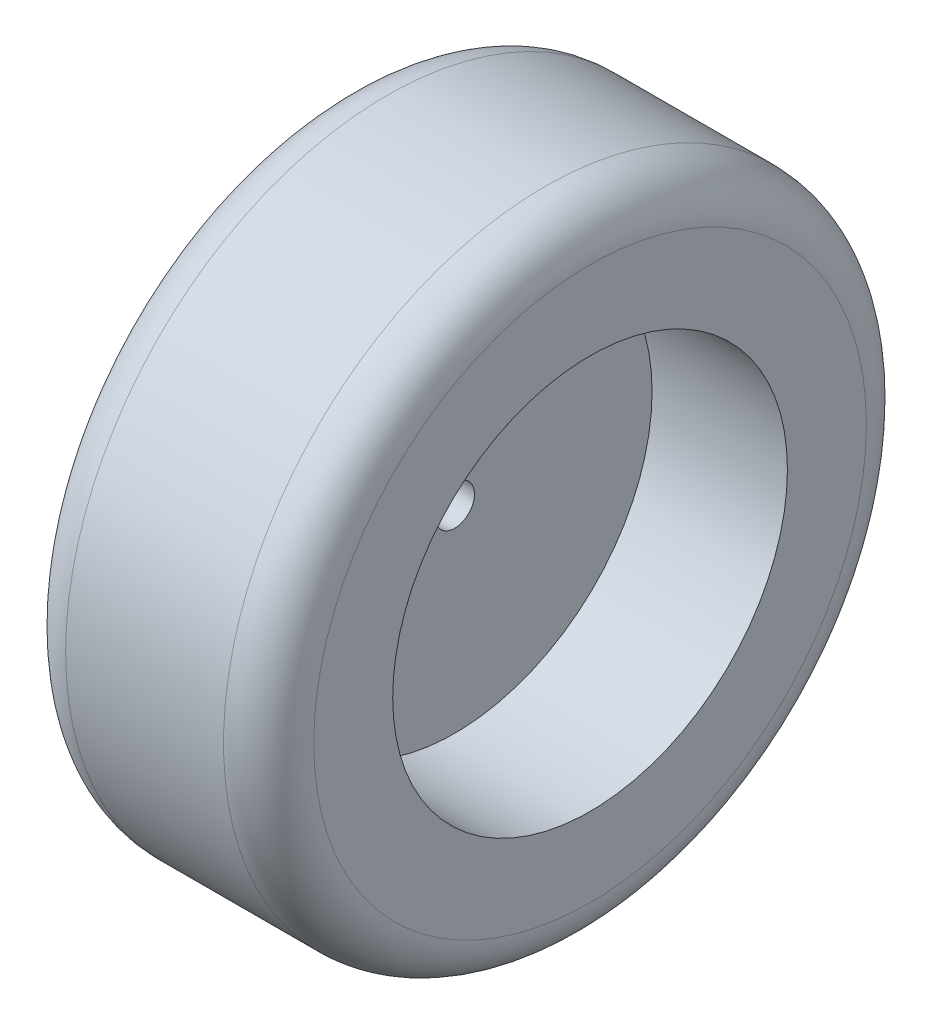
from build123d import *

# Parameters (mm, degrees)
SKETCH1_W          = 22
SKETCH1_H          = 28.5
FILLET1_R          = 4
SKETCH2_R          = 17.5
CUT_EXTRUDE1_DEPTH = 12
SKETCH3_R          = 17.5
CUT_EXTRUDE2_DEPTH = 8
SKETCH4_R          = 1.75
CUT_EXTRUDE3_DEPTH = 11


with BuildPart() as part:
    # Sketch1 → Revolve1 (revolve)
    with BuildSketch(Plane(origin=(0, 0, 0), x_dir=(1, 0, 0), z_dir=(0, 1, 0))):
        with Locations((0, 14.25)):
            Rectangle(SKETCH1_W, SKETCH1_H)
    revolve(axis=Axis((11, 0, 0), (-1, 0, 0)))

    # Fillet1
    fillet1_edges = [part.edges().sort_by_distance(p)[0] for p in [
        (11, 0, 28.5),
        (-11, 0, 28.5),
    ]]
    fillet(fillet1_edges, radius=FILLET1_R)

    # Sketch2 → Cut-Extrude1 (cut)
    with BuildSketch(Plane(origin=(11, 0, 0), x_dir=(0, 0, -1), z_dir=(1, 0, 0))):
        Circle(SKETCH2_R)
    extrude(amount=-CUT_EXTRUDE1_DEPTH, mode=Mode.SUBTRACT)

    # Sketch3 → Cut-Extrude2 (cut)
    with BuildSketch(Plane.ZY.offset(11)):
        Circle(SKETCH3_R)
    extrude(amount=-CUT_EXTRUDE2_DEPTH, mode=Mode.SUBTRACT)

    # Sketch4 → Cut-Extrude3 (cut, through all)
    with BuildSketch(Plane(origin=(-1, 0, 0), x_dir=(0, 0, -1), z_dir=(1, 0, 0))):
        Circle(SKETCH4_R)
    extrude(amount=-CUT_EXTRUDE3_DEPTH, mode=Mode.SUBTRACT)


solid = part.part
